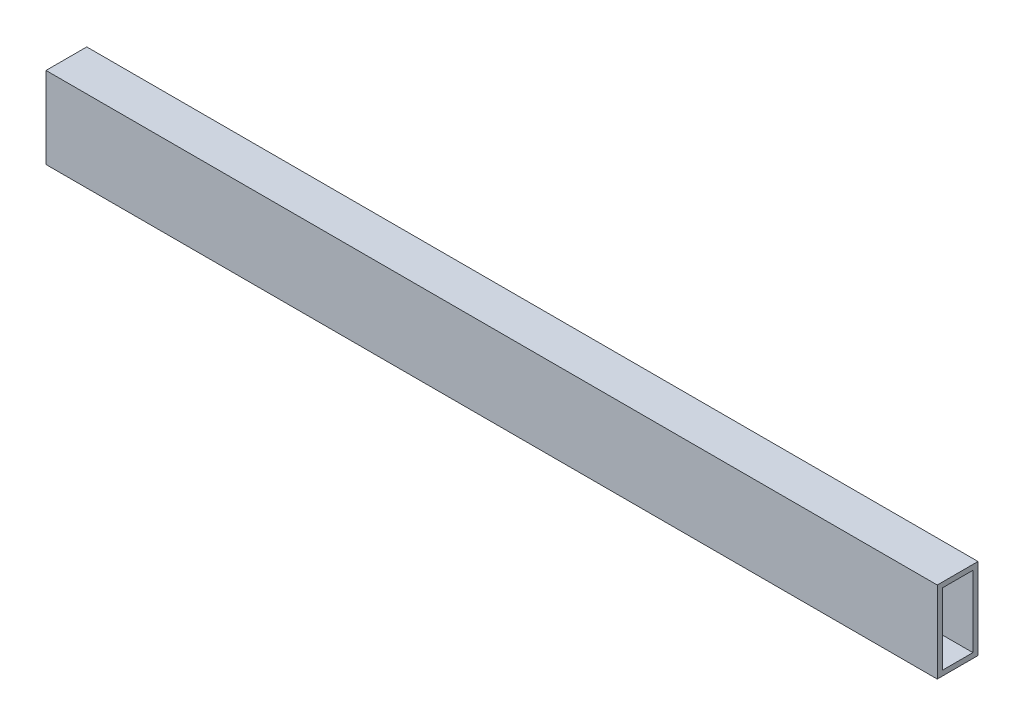
from build123d import *

# Parameters (mm, degrees)
SKETCH1_W           = 25.4
SKETCH1_H           = 50.8
SKETCH1_W_2         = 19.05
SKETCH1_H_2         = 44.45
BOSS_EXTRUDE1_DEPTH = 555.625


with BuildPart() as part:
    # Sketch1 → Boss-Extrude1 (new body)
    with BuildSketch(Plane(origin=(0, 0, 0), x_dir=(0, 0, -1), z_dir=(1, 0, 0))):
        with Locations((12.7, 25.4)):
            Rectangle(SKETCH1_W, SKETCH1_H)
        with Locations((12.7, 25.4)):
            Rectangle(SKETCH1_W_2, SKETCH1_H_2, mode=Mode.SUBTRACT)
    extrude(amount=BOSS_EXTRUDE1_DEPTH)


solid = part.part
